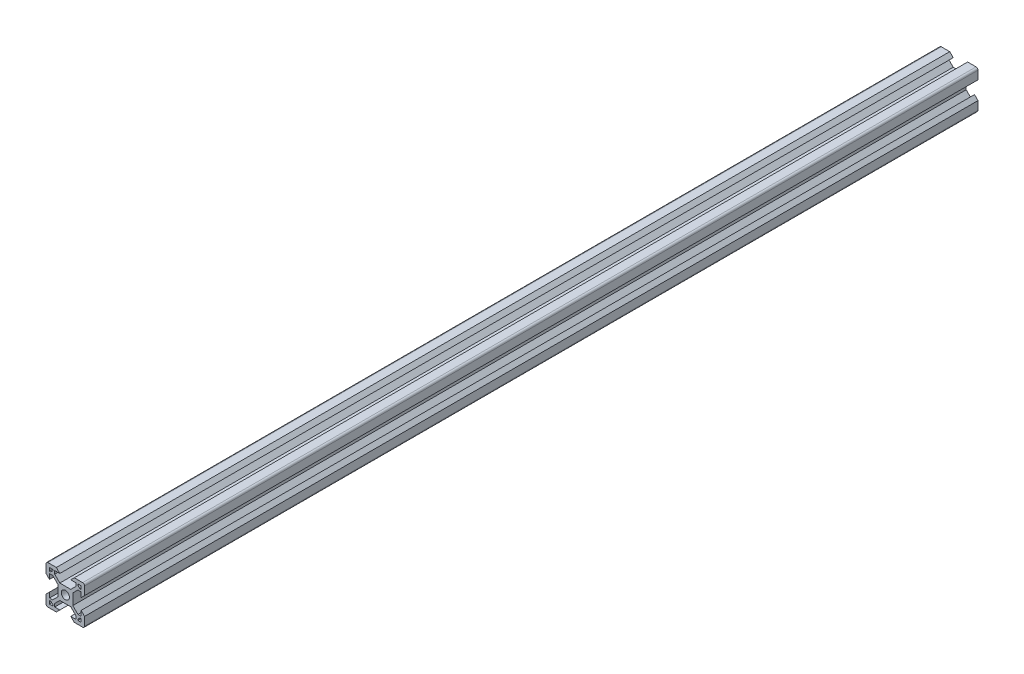
from build123d import *

# Parameters (mm, degrees)
SKETCH1_R           = 2.1
BOSS_EXTRUDE1_DEPTH = 463


with BuildPart() as part:
    # Sketch1 → Boss-Extrude1 (new body)
    with BuildSketch(Plane.XY):
        with BuildLine():
            Line((0, 1), (0, 5.36))
            Line((0, 5.36), (1.8, 7.16))
            Line((1.8, 7.16), (1.8, 4.500660172))
            Line((1.8, 4.500660172), (3.44, 4.500660172))
            Line((3.44, 4.500660172), (6.099339828, 7.16))
            Line((6.099339828, 7.16), (6.099339828, 12.84))
            Line((6.099339828, 12.84), (3.44, 15.499339828))
            Line((3.44, 15.499339828), (1.8, 15.499339828))
            Line((1.8, 15.499339828), (1.8, 12.84))
            Line((1.8, 12.84), (0, 14.64))
            Line((0, 14.64), (0, 19))
            ThreePointArc((0, 19), (0.292893219, 19.707106781), (1, 20))
            Line((1, 20), (5.36, 20))
            Line((5.36, 20), (7.16, 18.2))
            Line((7.16, 18.2), (4.500660172, 18.2))
            Line((4.500660172, 18.2), (4.500660172, 16.56))
            Line((4.500660172, 16.56), (7.16, 13.900660172))
            Line((7.16, 13.900660172), (12.84, 13.900660172))
            Line((12.84, 13.900660172), (15.464579042, 16.525239214))
            Line((15.464579042, 16.525239214), (15.464579042, 18.165239214))
            Line((15.464579042, 18.165239214), (12.84, 18.2))
            Line((12.84, 18.2), (14.64, 20))
            Line((14.64, 20), (19, 20))
            ThreePointArc((19, 20), (19.707106781, 19.707106781), (20, 19))
            Line((20, 19), (20, 14.674581351))
            Line((20, 14.674581351), (18.155899385, 12.84))
            Line((18.155899385, 12.84), (18.155899385, 15.455239214))
            Line((18.155899385, 15.455239214), (16.515899385, 15.455239214))
            Line((16.515899385, 15.455239214), (13.900660172, 12.84))
            Line((13.900660172, 12.84), (13.900660172, 7.16))
            Line((13.900660172, 7.16), (16.56, 4.500660172))
            Line((16.56, 4.500660172), (18.2, 4.500660172))
            Line((18.2, 4.500660172), (18.2, 7.16))
            Line((18.2, 7.16), (20, 5.36))
            Line((20, 5.36), (20, 1))
            ThreePointArc((20, 1), (19.707106781, 0.292893219), (19, 0))
            Line((19, 0), (14.64, 0))
            Line((14.64, 0), (12.84, 1.8))
            Line((12.84, 1.8), (15.499339828, 1.8))
            Line((15.499339828, 1.8), (15.499339828, 3.44))
            Line((15.499339828, 3.44), (12.84, 6.099339828))
            Line((12.84, 6.099339828), (7.16, 6.099339828))
            Line((7.16, 6.099339828), (4.500660172, 3.44))
            Line((4.500660172, 3.44), (4.500660172, 1.8))
            Line((4.500660172, 1.8), (7.16, 1.8))
            Line((7.16, 1.8), (5.36, 0))
            Line((5.36, 0), (1, 0))
            ThreePointArc((1, 0), (0.292893219, 0.292893219), (0, 1))
        make_face()
        with Locations((10.02040103, 9.97959897)):
            Circle(SKETCH1_R, mode=Mode.SUBTRACT)
        Polygon((16.534579042, 18.2), (16.534579042, 17.576559557), (17.585899385, 16.525239214), (18.2, 16.525239214), (18.2, 18.2), align=None, mode=Mode.SUBTRACT)
        Polygon((18.2, 1.75919794), (18.2, 3.433958726), (17.585899385, 3.433958726), (16.534579042, 2.382638382), (16.534579042, 1.75919794), align=None, mode=Mode.SUBTRACT)
        Polygon((2.454902675, 16.525239214), (1.84080206, 16.525239214), (1.84080206, 18.2), (3.506223018, 18.2), (3.506223018, 17.576559557), align=None, mode=Mode.SUBTRACT)
        Polygon((3.506223018, 1.75919794), (1.84080206, 1.75919794), (1.84080206, 3.433958726), (2.454902675, 3.433958726), (3.506223018, 2.382638382), align=None, mode=Mode.SUBTRACT)
    extrude(amount=-BOSS_EXTRUDE1_DEPTH)


solid = part.part
